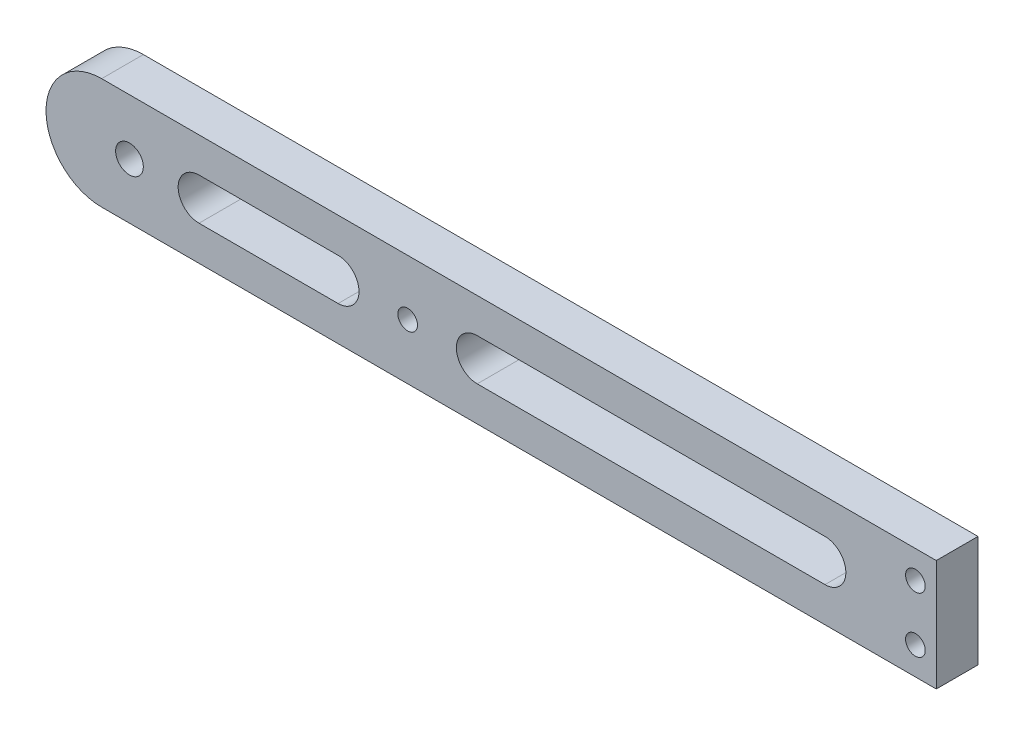
from build123d import *

# Parameters (mm, degrees)
SKETCH1_W                 = 203.2
SKETCH1_H                 = 25.4
BOSS_EXTRUDE1_DEPTH       = 9.525
F_8_CLEARANCE_HOLE1_D     = 4.4958
F_8_CLEARANCE_HOLE1_DEPTH = 25.4
F_8_CLEARANCE_HOLE1_TIP   = 1.350674586
SKETCH5_R                 = 3.1623
CUT_EXTRUDE1_DEPTH        = 9.525
F_8_CLEARANCE_HOLE2_D     = 4.4958
F_8_CLEARANCE_HOLE2_DEPTH = 19.05
F_8_CLEARANCE_HOLE2_TIP   = 1.350674586
CUT_EXTRUDE2_DEPTH        = 10.525
CUT_EXTRUDE3_DEPTH        = 10.525


with BuildPart() as part:
    # Sketch1 → Boss-Extrude1 (new body)
    with BuildSketch(Plane.XY):
        with Locations((-101.6, 12.7)):
            Rectangle(SKETCH1_W, SKETCH1_H)
    extrude(amount=BOSS_EXTRUDE1_DEPTH)

    # #8 Clearance Hole1
    with Locations(Plane.XY.offset(9.525)):
        with Locations((-4.7625, 6.35), (-4.7625, 19.05)):
            Hole(F_8_CLEARANCE_HOLE1_D / 2, depth=F_8_CLEARANCE_HOLE1_DEPTH)
            with Locations((0, 0, -(F_8_CLEARANCE_HOLE1_DEPTH + F_8_CLEARANCE_HOLE1_TIP / 2))):  # 118° drill point
                Cone(0, F_8_CLEARANCE_HOLE1_D / 2, F_8_CLEARANCE_HOLE1_TIP, mode=Mode.SUBTRACT)

    # Sketch5 → Cut-Extrude1 (cut)
    with BuildSketch(Plane.XY.offset(9.525)):
        with Locations((-184.15, 12.7)):
            Circle(SKETCH5_R)
    extrude(amount=-CUT_EXTRUDE1_DEPTH, mode=Mode.SUBTRACT)

    # #8 Clearance Hole2
    with Locations(Plane.XY.offset(9.525)):
        with Locations((-120.65, 12.7)):
            Hole(F_8_CLEARANCE_HOLE2_D / 2, depth=F_8_CLEARANCE_HOLE2_DEPTH)
            with Locations((0, 0, -(F_8_CLEARANCE_HOLE2_DEPTH + F_8_CLEARANCE_HOLE2_TIP / 2))):  # 118° drill point
                Cone(0, F_8_CLEARANCE_HOLE2_D / 2, F_8_CLEARANCE_HOLE2_TIP, mode=Mode.SUBTRACT)

    # Sketch10 → Cut-Extrude2 (cut, through all)
    with BuildSketch(Plane.XY.offset(9.525)):
        with BuildLine():
            Line((-190.5, 25.4), (-203.2, 25.4))
            Line((-203.2, 25.4), (-203.2, 12.7))
            ThreePointArc((-203.2, 12.7), (-199.480256121, 21.680256121), (-190.5, 25.4))
        make_face()
        with BuildLine():
            ThreePointArc((-190.5, 0), (-199.480256121, 3.719743879), (-203.2, 12.7))
            Line((-203.2, 12.7), (-203.2, 0))
            Line((-203.2, 0), (-190.5, 0))
        make_face()
    extrude(amount=-CUT_EXTRUDE2_DEPTH, mode=Mode.SUBTRACT)

    # Sketch11 → Cut-Extrude3 (cut, through all)
    with BuildSketch(Plane(origin=(0, 0, 0), x_dir=(-1, 0, 0), z_dir=(0, 0, -1))):
        with BuildLine():
            Line((25.4, 17.4625), (104.775, 17.4625))
            ThreePointArc((104.775, 17.4625), (109.5375, 12.7), (104.775, 7.9375))
            Line((104.775, 7.9375), (25.4, 7.9375))
            ThreePointArc((25.4, 7.9375), (20.6375, 12.7), (25.4, 17.4625))
        make_face()
        with BuildLine():
            Line((136.525, 17.4625), (168.275, 17.4625))
            ThreePointArc((168.275, 17.4625), (173.0375, 12.7), (168.275, 7.9375))
            Line((168.275, 7.9375), (136.525, 7.9375))
            ThreePointArc((136.525, 7.9375), (131.7625, 12.7), (136.525, 17.4625))
        make_face()
    extrude(amount=-CUT_EXTRUDE3_DEPTH, mode=Mode.SUBTRACT)


solid = part.part
